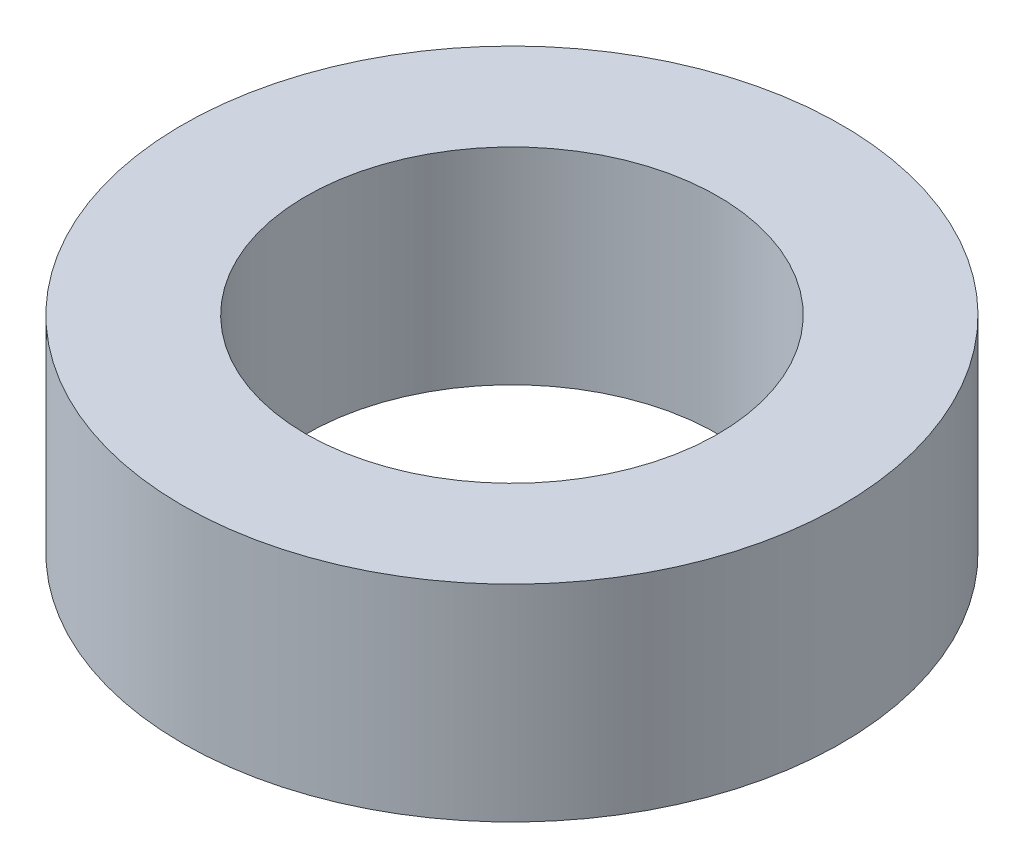
from build123d import *

# Parameters (mm, degrees)
SKETCH1_R           = 4
SKETCH1_R_2         = 2.5
BOSS_EXTRUDE1_DEPTH = 1.25


with BuildPart() as part:
    # Sketch1 → Boss-Extrude1 (new body, symmetric)
    with BuildSketch(Plane(origin=(0, 0, 0), x_dir=(1, 0, 0), z_dir=(0, 1, 0))):
        Circle(SKETCH1_R)
        Circle(SKETCH1_R_2, mode=Mode.SUBTRACT)
    extrude(amount=BOSS_EXTRUDE1_DEPTH, both=True)


solid = part.part
